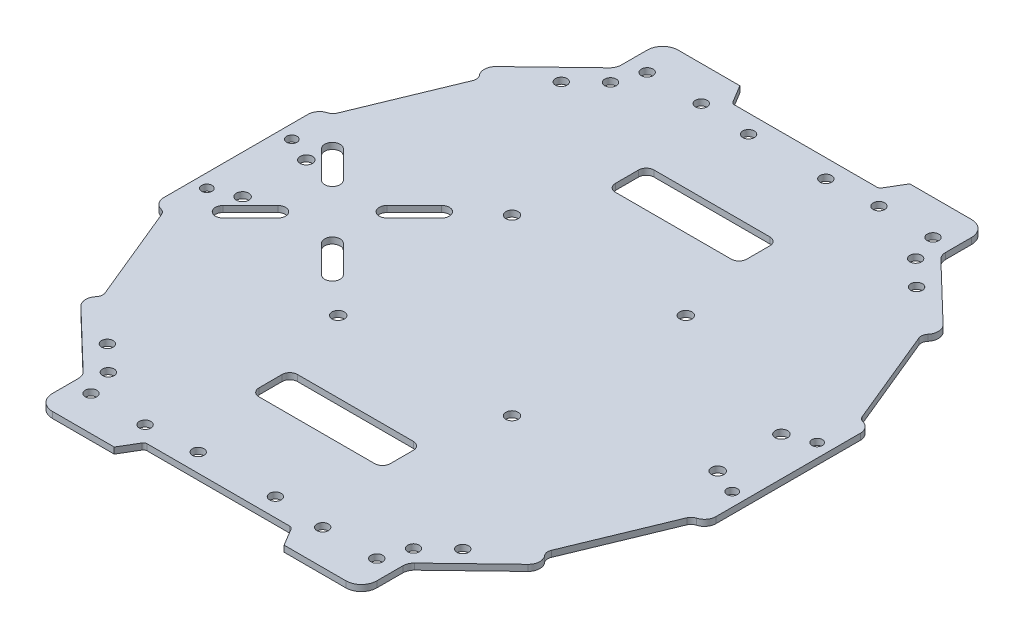
from build123d import *

# Parameters (mm, degrees)
SKETCH1_R          = 1.5
SKETCH1_R_2        = 1.35
SKETCH1_R_3        = 1.6
EXTRUSION1_DEPTH   = 1.6
FILLET1_R          = 1
FILLET2_R          = 4
FILLET3_R          = 3
FILLET4_R          = 3
FILLET5_R          = 2
FILLET6_R          = 2
FILLET7_R          = 3
FILLET8_R          = 3
FILLET9_R          = 2
FILLET10_R         = 2
FILLET11_R         = 3
CUT_EXTRUDE1_DEPTH = 10
CUT_EXTRUDE2_DEPTH = 10


with BuildPart() as part:
    # Sketch1 → Extrusion1 (new body)
    with BuildSketch(Plane(origin=(0, 0, 0), x_dir=(-1, 0, 0), z_dir=(0, 1, 0))):
        Polygon((78.775158519, 259.059874387), (59.775158519, 259.059874387), (56.775158519, 264.05987395), (36.775158519, 264.05987395), (36.775158519, 252.05987395), (18.755330752, 234.731117294), (21.527931817, 231.847944851), (10.275158581, 204.559863083), (7.275158519, 204.559863083), (7.275158519, 183.059873956), (7.275158519, 161.559884829), (10.275158581, 161.559884829), (21.527931817, 134.27180306), (18.755330752, 131.388630617), (36.775158519, 114.059873961), (36.775158519, 102.059873961), (56.775158519, 102.059873961), (59.775158519, 107.059873524), (78.775158519, 107.059873524), (97.775158519, 107.059873524), (100.775158519, 102.059873961), (120.775158519, 102.059873961), (120.775158519, 114.059873961), (138.794986286, 131.388630617), (136.022385221, 134.27180306), (147.275158457, 161.559884829), (150.275158519, 161.559884829), (150.275158519, 183.059873956), (150.275158519, 204.559863083), (147.275158457, 204.559863083), (136.022385221, 231.847944851), (138.794986286, 234.731117294), (120.775158519, 252.05987395), (120.775158519, 264.05987395), (100.775158519, 264.05987395), (97.775158519, 259.059874387), align=None)
        with Locations((41.775158457, 111.059884829)):
            Circle(SKETCH1_R, mode=Mode.SUBTRACT)
        with Locations((39.275158457, 118.059884829)):
            Circle(SKETCH1_R, mode=Mode.SUBTRACT)
        with Locations((32.775158457, 124.309884829)):
            Circle(SKETCH1_R, mode=Mode.SUBTRACT)
        with Locations((10.775158457, 172.059872631)):
            Circle(SKETCH1_R_2, mode=Mode.SUBTRACT)
        with Locations((17.275158457, 174.809872631)):
            Circle(SKETCH1_R_3, mode=Mode.SUBTRACT)
        with Locations((55.775158457, 111.059872631)):
            Circle(SKETCH1_R, mode=Mode.SUBTRACT)
        with Locations((68.775158457, 111.809884829)):
            Circle(SKETCH1_R, mode=Mode.SUBTRACT)
        with Locations((88.775158581, 111.809884829)):
            Circle(SKETCH1_R, mode=Mode.SUBTRACT)
        with Locations((101.775158581, 111.059872631)):
            Circle(SKETCH1_R, mode=Mode.SUBTRACT)
        with Locations((115.775158581, 111.059884829)):
            Circle(SKETCH1_R, mode=Mode.SUBTRACT)
        with Locations((118.275158581, 118.059884829)):
            Circle(SKETCH1_R, mode=Mode.SUBTRACT)
        with Locations((124.775158581, 124.309884829)):
            Circle(SKETCH1_R, mode=Mode.SUBTRACT)
        with Locations((56.275158519, 160.559873956)):
            Circle(SKETCH1_R_3, mode=Mode.SUBTRACT)
        with Locations((101.275158519, 160.559873956)):
            Circle(SKETCH1_R_3, mode=Mode.SUBTRACT)
        with Locations((146.775158581, 172.059872631)):
            Circle(SKETCH1_R_2, mode=Mode.SUBTRACT)
        with Locations((140.275158581, 174.809872631)):
            Circle(SKETCH1_R_3, mode=Mode.SUBTRACT)
        with Locations((17.275158457, 191.30987528)):
            Circle(SKETCH1_R_3, mode=Mode.SUBTRACT)
        with Locations((10.775158457, 194.05987528)):
            Circle(SKETCH1_R_2, mode=Mode.SUBTRACT)
        with Locations((32.775158457, 241.809863083)):
            Circle(SKETCH1_R, mode=Mode.SUBTRACT)
        with Locations((39.275158457, 248.059863083)):
            Circle(SKETCH1_R, mode=Mode.SUBTRACT)
        with Locations((41.775158457, 255.059863083)):
            Circle(SKETCH1_R, mode=Mode.SUBTRACT)
        with Locations((56.275158519, 205.559873956)):
            Circle(SKETCH1_R_3, mode=Mode.SUBTRACT)
        with Locations((140.275158581, 191.30987528)):
            Circle(SKETCH1_R_3, mode=Mode.SUBTRACT)
        with Locations((146.775158581, 194.05987528)):
            Circle(SKETCH1_R_2, mode=Mode.SUBTRACT)
        with Locations((101.275158519, 205.559873956)):
            Circle(SKETCH1_R_3, mode=Mode.SUBTRACT)
        with Locations((55.775158457, 255.05987528)):
            Circle(SKETCH1_R, mode=Mode.SUBTRACT)
        with Locations((68.775158457, 254.309863083)):
            Circle(SKETCH1_R, mode=Mode.SUBTRACT)
        with Locations((88.775158581, 254.309863083)):
            Circle(SKETCH1_R, mode=Mode.SUBTRACT)
        with Locations((124.775158581, 241.809863083)):
            Circle(SKETCH1_R, mode=Mode.SUBTRACT)
        with Locations((118.275158581, 248.059863083)):
            Circle(SKETCH1_R, mode=Mode.SUBTRACT)
        with Locations((101.775158581, 255.05987528)):
            Circle(SKETCH1_R, mode=Mode.SUBTRACT)
        with Locations((115.775158581, 255.059863083)):
            Circle(SKETCH1_R, mode=Mode.SUBTRACT)
    extrude(amount=EXTRUSION1_DEPTH)

    # Fillet1
    fillet1_edges = [part.edges().sort_by_distance(p)[0] for p in [
        (-97.775158519, 0.8, 259.059874387),
        (-97.775158519, 0.8, 107.059873524),
        (-59.775158519, 0.8, 107.059873524),
        (-59.775158519, 0.8, 259.059874387),
    ]]
    fillet(fillet1_edges, radius=FILLET1_R)

    # Fillet2
    fillet2_edges = [part.edges().sort_by_distance(p)[0] for p in [
        (-120.775158519, 0.8, 264.05987395),
        (-120.775158519, 0.8, 102.059873961),
        (-36.775158519, 0.8, 102.059873961),
        (-36.775158519, 0.8, 264.05987395),
    ]]
    fillet(fillet2_edges, radius=FILLET2_R)

    # Fillet3
    fillet3_edges = [part.edges().sort_by_distance(p)[0] for p in [
        (-120.775158519, 0.8, 252.05987395),
        (-120.775158519, 0.8, 114.059873961),
        (-36.775158519, 0.8, 114.059873961),
        (-36.775158519, 0.8, 252.05987395),
    ]]
    fillet(fillet3_edges, radius=FILLET3_R)

    # Fillet4
    fillet4_edges = [part.edges().sort_by_distance(p)[0] for p in [
        (-138.794986286, 0.8, 234.731117294),
    ]]
    fillet(fillet4_edges, radius=FILLET4_R)

    # Fillet5
    fillet5_edges = [part.edges().sort_by_distance(p)[0] for p in [
        (-136.022385221, 0.8, 231.847944851),
    ]]
    fillet(fillet5_edges, radius=FILLET5_R)

    # Fillet6
    fillet6_edges = [part.edges().sort_by_distance(p)[0] for p in [
        (-21.527931817, 0.8, 231.847944851),
    ]]
    fillet(fillet6_edges, radius=FILLET6_R)

    # Fillet7
    fillet7_edges = [part.edges().sort_by_distance(p)[0] for p in [
        (-18.755330752, 0.8, 234.731117294),
    ]]
    fillet(fillet7_edges, radius=FILLET7_R)

    # Fillet8
    fillet8_edges = [part.edges().sort_by_distance(p)[0] for p in [
        (-138.794986286, 0.8, 131.388630617),
        (-18.755330752, 0.8, 131.388630617),
    ]]
    fillet(fillet8_edges, radius=FILLET8_R)

    # Fillet9
    fillet9_edges = [part.edges().sort_by_distance(p)[0] for p in [
        (-21.527931817, 0.8, 134.27180306),
        (-136.022385221, 0.8, 134.27180306),
    ]]
    fillet(fillet9_edges, radius=FILLET9_R)

    # Fillet10
    fillet10_edges = [part.edges().sort_by_distance(p)[0] for p in [
        (-147.275158457, 0.8, 204.559863083),
        (-147.275158457, 0.8, 161.559884829),
        (-10.275158581, 0.8, 161.559884829),
        (-10.275158581, 0.8, 204.559863083),
    ]]
    fillet(fillet10_edges, radius=FILLET10_R)

    # Fillet11
    fillet11_edges = [part.edges().sort_by_distance(p)[0] for p in [
        (-150.275158519, 0.8, 161.559884829),
        (-150.275158519, 0.8, 204.559863083),
        (-7.275158519, 0.8, 204.559863083),
        (-7.275158519, 0.8, 161.559884829),
    ]]
    fillet(fillet11_edges, radius=FILLET11_R)

    # Sketch2 → Cut-Extrude1 (cut)
    with BuildSketch(Plane(origin=(0, 1.6, 0), x_dir=(1, 0, 0), z_dir=(0, 1, 0))):
        with BuildLine():
            Line((-93.009489329, -132.059873524), (-63.009489329, -132.059873524))
            ThreePointArc((-63.009489329, -132.059873524), (-61.595275767, -132.645659962), (-61.009489329, -134.059873524))
            Line((-61.009489329, -134.059873524), (-61.009489329, -140.059873524))
            ThreePointArc((-61.009489329, -140.059873524), (-61.595275767, -141.474087087), (-63.009489329, -142.059873524))
            Line((-63.009489329, -142.059873524), (-93.009489329, -142.059873524))
            ThreePointArc((-93.009489329, -142.059873524), (-94.423702892, -141.474087087), (-95.009489329, -140.059873524))
            Line((-95.009489329, -140.059873524), (-95.009489329, -134.059873524))
            ThreePointArc((-95.009489329, -134.059873524), (-94.423702892, -132.645659962), (-93.009489329, -132.059873524))
        make_face()
        with BuildLine():
            Line((-93.30360653, -224.059874387), (-63.30360653, -224.059874387))
            ThreePointArc((-63.30360653, -224.059874387), (-61.889392968, -224.645660825), (-61.30360653, -226.059874387))
            Line((-61.30360653, -226.059874387), (-61.30360653, -232.059874387))
            ThreePointArc((-61.30360653, -232.059874387), (-61.889392968, -233.474087949), (-63.30360653, -234.059874387))
            Line((-63.30360653, -234.059874387), (-93.30360653, -234.059874387))
            ThreePointArc((-93.30360653, -234.059874387), (-94.717820093, -233.474087949), (-95.30360653, -232.059874387))
            Line((-95.30360653, -232.059874387), (-95.30360653, -226.059874387))
            ThreePointArc((-95.30360653, -226.059874387), (-94.717820093, -224.645660825), (-93.30360653, -224.059874387))
        make_face()
    extrude(amount=-CUT_EXTRUDE1_DEPTH, mode=Mode.SUBTRACT)

    # Sketch3 → Cut-Extrude2 (cut)
    with BuildSketch(Plane(origin=(0, 1.6, 0), x_dir=(1, 0, 0), z_dir=(0, 1, 0))):
        with BuildLine():
            Line((-119.61830427, -174.574592581), (-112.547236458, -167.50352477))
            ThreePointArc((-112.547236458, -167.50352477), (-109.718809333, -167.50352477), (-109.718809333, -170.331951894))
            Line((-109.718809333, -170.331951894), (-116.789877145, -177.403019706))
            ThreePointArc((-116.789877145, -177.403019706), (-119.61830427, -177.403019706), (-119.61830427, -174.574592581))
        make_face()
        with BuildLine():
            Line((-140.831507705, -195.787796017), (-133.760439894, -188.716728205))
            ThreePointArc((-133.760439894, -188.716728205), (-130.932012769, -188.716728205), (-130.932012769, -191.54515533))
            Line((-130.932012769, -191.54515533), (-138.003080581, -198.616223142))
            ThreePointArc((-138.003080581, -198.616223142), (-140.831507705, -198.616223142), (-140.831507705, -195.787796017))
        make_face()
        with BuildLine():
            Line((-138.003080581, -167.50352477), (-130.932012769, -174.574592581))
            ThreePointArc((-130.932012769, -174.574592581), (-130.932012769, -177.403019706), (-133.760439894, -177.403019706))
            Line((-133.760439894, -177.403019706), (-140.831507705, -170.331951894))
            ThreePointArc((-140.831507705, -170.331951894), (-140.831507705, -167.50352477), (-138.003080581, -167.50352477))
        make_face()
        with BuildLine():
            Line((-116.789877145, -188.716728205), (-109.718809333, -195.787796017))
            ThreePointArc((-109.718809333, -195.787796017), (-109.718809333, -198.616223142), (-112.547236458, -198.616223142))
            Line((-112.547236458, -198.616223142), (-119.61830427, -191.54515533))
            ThreePointArc((-119.61830427, -191.54515533), (-119.61830427, -188.716728205), (-116.789877145, -188.716728205))
        make_face()
    extrude(amount=-CUT_EXTRUDE2_DEPTH, mode=Mode.SUBTRACT)


solid = part.part
